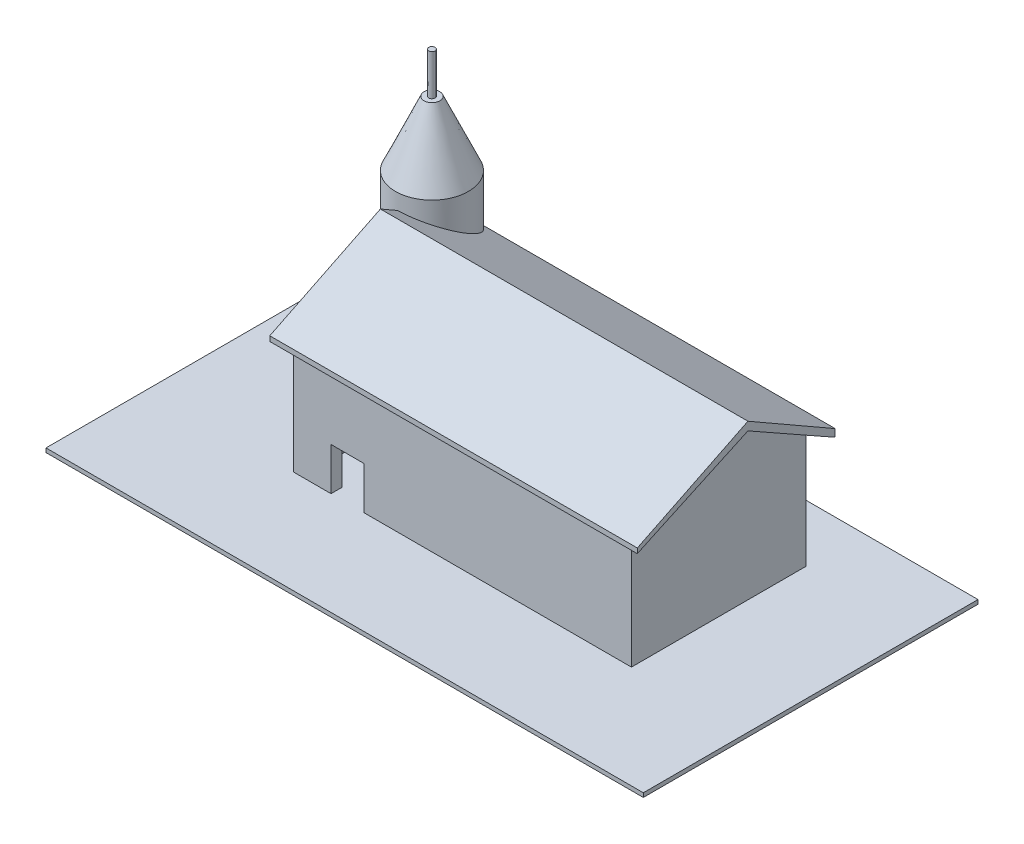
from build123d import *

# Parameters (mm, degrees)
SKETCH1_W                 = 146.259710098
SKETCH1_H                 = 81.954365634
BOSS_EXTRUDE1_DEPTH       = 1
BOSS_EXTRUDE3_DEPTH       = 30
SKETCH3_R                 = 8.932317163
BOSS_EXTRUDE4_DEPTH       = 30
CHAMFER2_SIZE             = 7
CHAMFER2_SIZE2            = 15.722257417
SKETCH5_R                 = 0.765790516
BOSS_EXTRUDE5_DEPTH       = 10
BOSS_EXTRUDE10_DEPTH      = 82.756209
BOSS_EXTRUDE11_DEPTH      = 5
BOSS_EXTRUDE11_DEPTH_BACK = 85
CUT_EXTRUDE1_REACH        = 58.766
SKETCH9_W                 = 8.019759774
SKETCH9_H                 = 10.43964337


with BuildPart() as part:
    # Sketch1 → Boss-Extrude1 (new body)
    with BuildSketch(Plane(origin=(0, 0, 0), x_dir=(1, 0, 0), z_dir=(0, 1, 0))):
        with Locations((4.257398588, 4.671362068)):
            Rectangle(SKETCH1_W, SKETCH1_H)
    extrude(amount=BOSS_EXTRUDE1_DEPTH)

    # Sketch2 → Boss-Extrude3 (add)
    with BuildSketch(Plane(origin=(0, 1, 0), x_dir=(1, 0, 0), z_dir=(0, 1, 0))):
        with BuildLine():
            Line((49.289390862, 31.61533336), (49.289390862, -11.117740331))
            Line((49.289390862, -11.117740331), (-33.466817923, -11.117740331))
            Line((-33.466817923, -11.117740331), (-33.466817923, 17.014992699))
            ThreePointArc((-33.466817923, 17.014992699), (-44.839654232, 27.770758355), (-29.665757449, 31.61533336))
            Line((-29.665757449, 31.61533336), (49.289390862, 31.61533336))
        make_face()
        with BuildLine():
            Line((-31.384885653, 21.995593928), (-31.384885653, -8.380062495))
            Line((-31.384885653, -8.380062495), (47.074717384, -8.380062495))
            Line((47.074717384, -8.380062495), (47.074717384, 28.596341433))
            Line((47.074717384, 28.596341433), (-31.086300879, 28.596341433))
            ThreePointArc((-31.086300879, 28.596341433), (-42.153064375, 25.789819421), (-31.384885653, 21.995593928))
        make_face(mode=Mode.SUBTRACT)
    extrude(amount=BOSS_EXTRUDE3_DEPTH)

    # Sketch3 → Boss-Extrude4 (add)
    with BuildSketch(Plane(origin=(0, 31, 0), x_dir=(1, 0, 0), z_dir=(0, 1, 0))):
        with Locations((-36.195473967, 25.520327854)):
            Circle(SKETCH3_R)
    extrude(amount=BOSS_EXTRUDE4_DEPTH)

    # Chamfer2
    chamfer2_edges = [part.edges().sort_by_distance(p)[0] for p in [
        (-45.12779113, 61, -25.520327854),
    ]]
    chamfer2_side = [part.faces().sort_by_distance(p)[0] for p in [
        (-36.195473967, 61, -25.520327854),
    ]]
    chamfer(chamfer2_edges, length=CHAMFER2_SIZE, length2=CHAMFER2_SIZE2, reference=chamfer2_side[0])

    # Sketch5 → Boss-Extrude5 (add)
    with BuildSketch(Plane(origin=(0, 61, 0), x_dir=(1, 0, 0), z_dir=(0, 1, 0))):
        with Locations((-36.195473967, 25.520327854)):
            Circle(SKETCH5_R)
    extrude(amount=BOSS_EXTRUDE5_DEPTH)

    # Sketch7 → Boss-Extrude10 (add)
    with BuildSketch(Plane(origin=(49.289390862, 0, 0), x_dir=(0, 0, -1), z_dir=(1, 0, 0))):
        Polygon((-11.117740331, 31), (12.411619963, 41.835751537), (31.61533336, 31), align=None)
    extrude(amount=-BOSS_EXTRUDE10_DEPTH)

    # Sketch8 → Boss-Extrude11 (add, two sides)
    with BuildSketch(Plane(origin=(49.289390862, 0, 0), x_dir=(0, 0, -1), z_dir=(1, 0, 0))) as boss_extrude11_sk:
        Polygon((-11.117740331, 31), (12.411619963, 41.835751537), (31.61533336, 31), (33.773667087, 29.849066987), (33.773667087, 31.638529108), (12.411619963, 43.882217303), (-14.672774477, 30.545550786), (-14.672774477, 29.330586748), align=None)
    extrude(amount=BOSS_EXTRUDE11_DEPTH)
    extrude(boss_extrude11_sk.sketch, amount=-BOSS_EXTRUDE11_DEPTH_BACK)

    # Sketch9 → Cut-Extrude1 (cut, up to next)
    with BuildSketch(Plane.XY.offset(11.117740331), mode=Mode.PRIVATE) as cut_extrude1_sk1:
        with Locations((-20.260430368, 6.219821685)):
            Rectangle(SKETCH9_W, SKETCH9_H)
    cut_extrude1_tool1 = extrude(cut_extrude1_sk1.sketch, amount=-CUT_EXTRUDE1_REACH, mode=Mode.PRIVATE) & part.part
    add(cut_extrude1_tool1.solids().sort_by_distance((-20.26043, 6.219822, 11.11774))[0], mode=Mode.SUBTRACT)


solid = part.part
